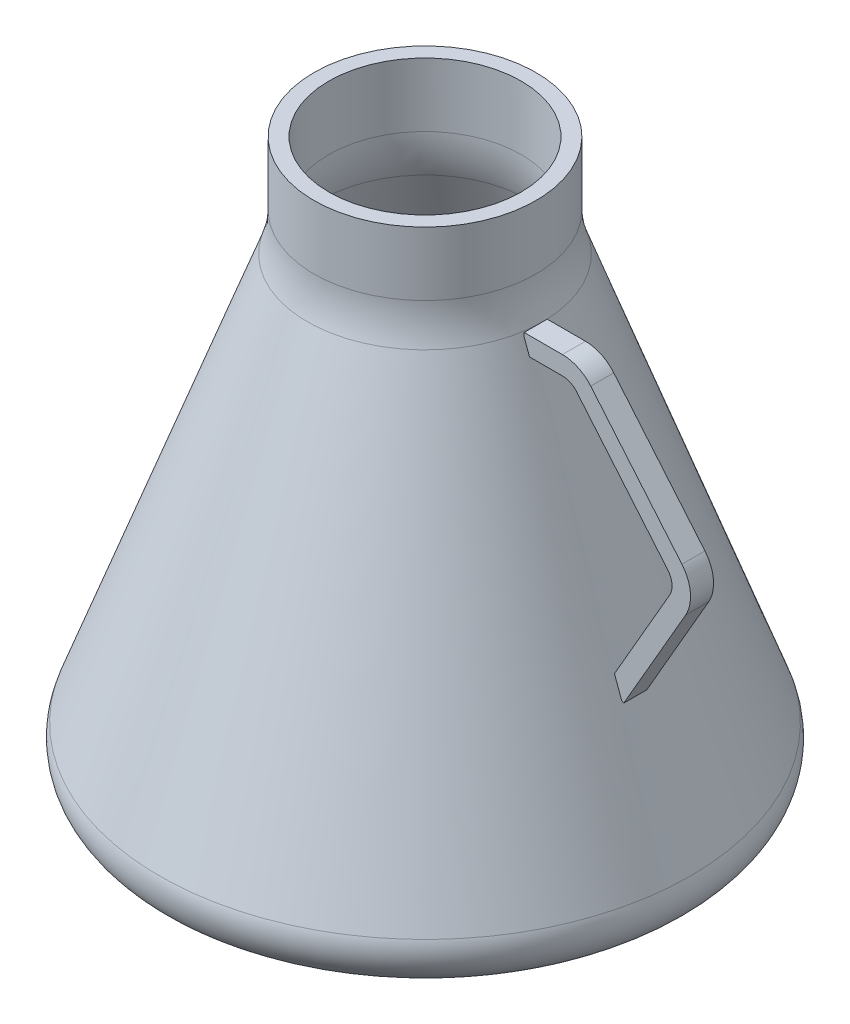
from build123d import *

# Parameters (mm, degrees)
SHELL1_T                 = -8
FILLET1_R                = 12
FILLET3_R                = 20
EXTRUDE_THIN1_DEPTH      = 10
EXTRUDE_THIN1_DEPTH_BACK = 2.451833806


with BuildPart() as part:
    # Sketch2 → Revolve2 (revolve)
    with BuildSketch(Plane.XY):
        with BuildLine():
            Line((-8.874501992, 12.639442231), (-8.874501992, -21.780938926))
            ThreePointArc((-8.874501992, -21.780938926), (-9.786036811, -32.199829586), (-12.492944745, -42.302147526))
            Line((-12.492944745, -42.302147526), (-102.176418507, -288.705466585))
            Line((-102.176418507, -288.705466585), (51.125498008, -288.705466585))
            Line((51.125498008, -288.705466585), (51.125498008, 12.639442231))
            Line((51.125498008, 12.639442231), (-8.874501992, 12.639442231))
        make_face()
    revolve(axis=Axis((51.125498008, 12.639442231, 0), (0, -1, 0)))

    # Shell1
    shell1_openings = [part.faces().sort_by_distance(p)[0] for p in [
        (51.125498008, 12.639442231, 0),
    ]]
    offset(amount=SHELL1_T, openings=shell1_openings, kind=Kind.INTERSECTION)

    # Fillet1
    fillet1_edges = [part.edges().sort_by_distance(p)[0] for p in [
        (193.002230469, -280.705466585, 0),
    ]]
    fillet(fillet1_edges, radius=FILLET1_R)

    # Fillet3
    fillet3_edges = [part.edges().sort_by_distance(p)[0] for p in [
        (204.427414523, -288.705466585, 0),
    ]]
    fillet(fillet3_edges, radius=FILLET3_R)

    # Sketch3 → Extrude-Thin1 (add, two sides)
    with BuildSketch(Plane.XY) as extrude_thin1_sk:
        with BuildLine():
            Line((114.743940761, -42.302147526), (135.417787598, -42.302147526))
            ThreePointArc((135.417787598, -42.302147526), (143.870152833, -44.175991785), (150.73867646, -49.446395332))
            Line((150.73867646, -49.446395332), (200.021007134, -108.178789964))
            ThreePointArc((200.021007134, -108.178789964), (204.624012234, -119.291427303), (202.020626347, -131.034542158))
            Line((202.020626347, -131.034542158), (168.608182886, -188.906591838))
            Line((168.608182886, -188.906591838), (159.947928848, -183.906591838))
            Line((159.947928848, -183.906591838), (193.36037231, -126.034542158))
            ThreePointArc((193.36037231, -126.034542158), (194.662065253, -120.162984731), (192.360562703, -114.606666061))
            Line((192.360562703, -114.606666061), (143.078232029, -55.874271429))
            ThreePointArc((143.078232029, -55.874271429), (139.643970215, -53.239069656), (135.417787598, -52.302147526))
            Line((135.417787598, -52.302147526), (114.743940761, -52.302147526))
            Line((114.743940761, -52.302147526), (114.743940761, -42.302147526))
        make_face()
    extrude(amount=EXTRUDE_THIN1_DEPTH)
    extrude(extrude_thin1_sk.sketch, amount=-EXTRUDE_THIN1_DEPTH_BACK)


solid = part.part
